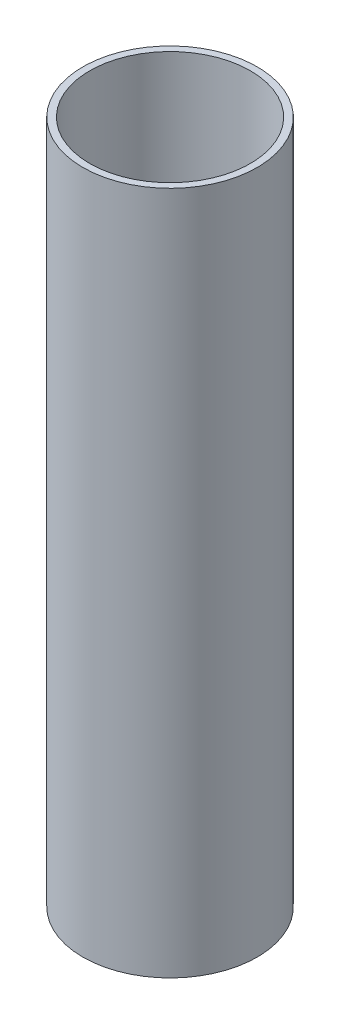
from build123d import *

# Parameters (mm, degrees)
SKETCH1_R           = 25.5
SKETCH1_R_2         = 23.5
BOSS_EXTRUDE1_DEPTH = 200


with BuildPart() as part:
    # Sketch1 → Boss-Extrude1 (new body)
    with BuildSketch(Plane(origin=(0, 0, 0), x_dir=(1, 0, 0), z_dir=(0, 1, 0))):
        Circle(SKETCH1_R)
        Circle(SKETCH1_R_2, mode=Mode.SUBTRACT)
    extrude(amount=BOSS_EXTRUDE1_DEPTH)

    # Sketch2 → Revolve1 (revolve)
    with BuildSketch(Plane.XY):
        with BuildLine():
            Line((-23.5, 0), (-5, 0))
            ThreePointArc((-5, 0), (-3.535533906, 3.535533906), (0, 5))
            Line((0, 5), (0, 7))
            ThreePointArc((0, 7), (-4.183300133, 5.61248608), (-6.708203932, 2))
            Line((-6.708203932, 2), (-23.5, 2))
            Line((-23.5, 2), (-23.5, 0))
        make_face()
    revolve(axis=Axis((0, 5, 0), (0, 1, 0)))


solid = part.part
